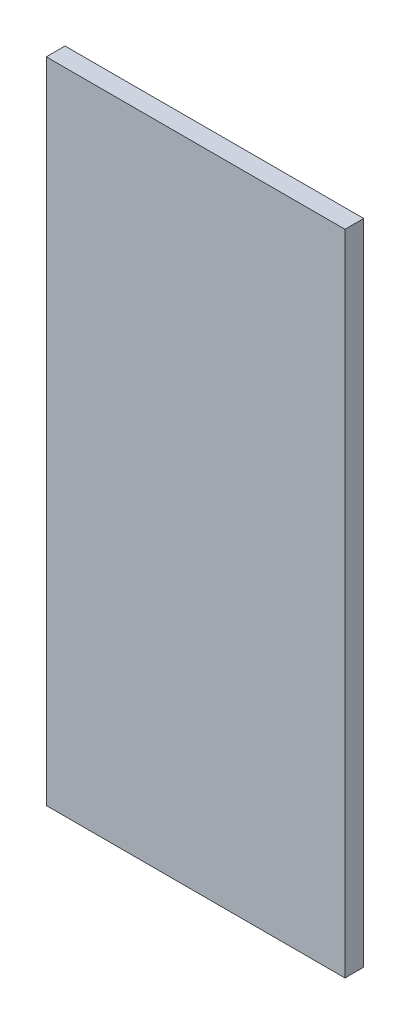
from build123d import *

# Parameters (mm, degrees)
SKETCH1_W           = 287
SKETCH1_H           = 623
BOSS_EXTRUDE1_DEPTH = 18


with BuildPart() as part:
    # Sketch1 → Boss-Extrude1 (new body)
    with BuildSketch(Plane.XY):
        Rectangle(SKETCH1_W, SKETCH1_H)
    extrude(amount=BOSS_EXTRUDE1_DEPTH)


solid = part.part
